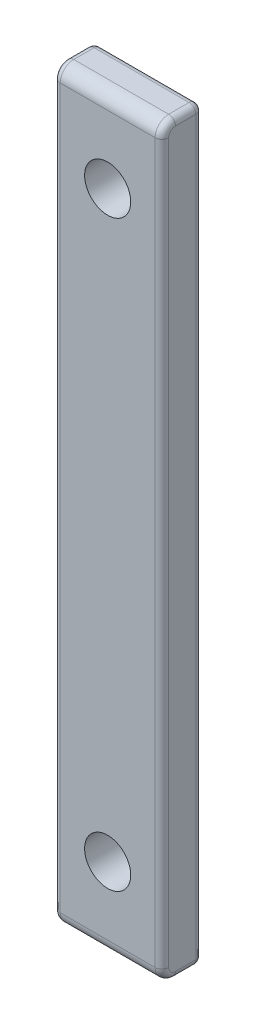
from build123d import *

# Parameters (mm, degrees)
SKETCH1_W           = 55
SKETCH1_H           = 8
BOSS_EXTRUDE1_DEPTH = 3
SKETCH2_R           = 1.7
CUT_EXTRUDE1_DEPTH  = 3
FILLET2_R           = 1
FILLET3_R           = 0.5
FILLET4_R           = 0.5


with BuildPart() as part:
    # Sketch1 → Boss-Extrude1 (new body)
    with BuildSketch(Plane(origin=(0, 0, 0), x_dir=(0, 1, 0), z_dir=(0, 0, 1))):
        Rectangle(SKETCH1_W, SKETCH1_H)
    extrude(amount=BOSS_EXTRUDE1_DEPTH)

    # Sketch2 → Cut-Extrude1 (cut)
    with BuildSketch(Plane.XY.offset(3)):
        with Locations((0, 21.5)):
            Circle(SKETCH2_R)
        with Locations((0, -21.5)):
            Circle(SKETCH2_R)
    extrude(amount=-CUT_EXTRUDE1_DEPTH, mode=Mode.SUBTRACT)

    # Fillet2
    fillet2_edges = [part.edges().sort_by_distance(p)[0] for p in [
        (0, 27.5, 3),
        (0, -27.5, 3),
    ]]
    fillet(fillet2_edges, radius=FILLET2_R)

    # Fillet3
    fillet3_edges = [part.edges().sort_by_distance(p)[0] for p in [
        (4, 0, 3),
        (-4, 0, 3),
        (4, 27.5, 1),
        (4, -27.5, 1),
        (4, 27.207106781, 2.707106781),
        (4, -27.207106781, 2.707106781),
        (-4, -27.5, 1),
        (-4, 27.5, 1),
        (-4, 27.207106781, 2.707106781),
        (-4, -27.207106781, 2.707106781),
    ]]
    fillet(fillet3_edges, radius=FILLET3_R)

    # Fillet4
    fillet4_edges = [part.edges().sort_by_distance(p)[0] for p in [
        (4, 0, 0),
        (0, -27.5, 0),
        (-4, 0, 0),
        (0, 27.5, 0),
        (-3.853553391, -27.353553391, 0),
        (-3.853553391, 27.353553391, 0),
        (3.853553391, 27.353553391, 0),
        (3.853553391, -27.353553391, 0),
    ]]
    fillet(fillet4_edges, radius=FILLET4_R)


solid = part.part
